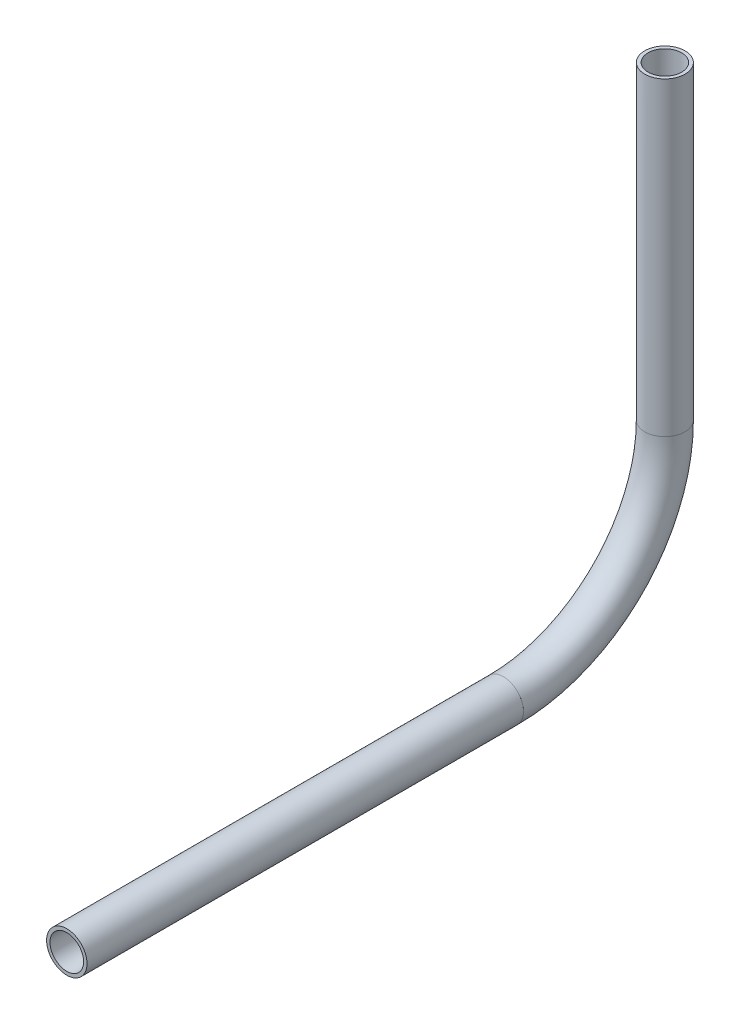
from build123d import *

# Parameters (mm, degrees)
SKETCH11_R                = 6.35
SKETCH11_R_2              = 5.2832
PIPE_0_5_SCH_40_1_DEPTH   = 137.277114131
SKETCH11_ON_SEGMENT_2_R   = 6.35
SKETCH11_ON_SEGMENT_2_R_2 = 5.2832
PIPE_0_5_SCH_40_1_2_ANGLE = 90
SKETCH11_ON_SEGMENT_3_R   = 6.35
SKETCH11_ON_SEGMENT_3_R_2 = 5.2832
PIPE_0_5_SCH_40_1_3_DEPTH = 97.413797302


with BuildPart() as part:
    # Sketch11 → Pipe 0.5 SCH 40(1) (new body)
    with BuildSketch(Plane(origin=(0, 599.960019272, 303.164595711), x_dir=(0, 1, 0), z_dir=(0, 0, -1))):
        Circle(SKETCH11_R)
        Circle(SKETCH11_R_2, mode=Mode.SUBTRACT)
    extrude(amount=PIPE_0_5_SCH_40_1_DEPTH)


with BuildPart() as body_2:
    # Sketch11 on segment 2 (carried to the start of arc 2) → Pipe 0.5 SCH 40_1 2 (revolve)
    with BuildSketch(Plane(origin=(0, 599.960019272, 165.88748158), x_dir=(0, 1, 0), z_dir=(0, 0, -1))):
        Circle(SKETCH11_ON_SEGMENT_2_R)
        Circle(SKETCH11_ON_SEGMENT_2_R_2, mode=Mode.SUBTRACT)
    revolve(axis=Axis((0, 650.760019272, 165.88748158), (1, 0, 0)), revolution_arc=PIPE_0_5_SCH_40_1_2_ANGLE)


with BuildPart() as body_3:
    # Sketch11 on segment 3 (carried to segment 3) → Pipe 0.5 SCH 40_1 3 (new body)
    with BuildSketch(Plane(origin=(0, 650.760019272, 115.08748158), x_dir=(0, 0, 1), z_dir=(0, 1, 0))):
        Circle(SKETCH11_ON_SEGMENT_3_R)
        Circle(SKETCH11_ON_SEGMENT_3_R_2, mode=Mode.SUBTRACT)
    extrude(amount=PIPE_0_5_SCH_40_1_3_DEPTH)


solid = Compound([part.part, body_2.part, body_3.part])
